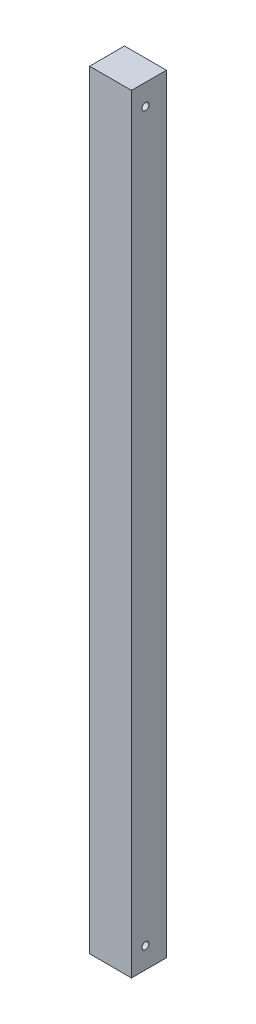
from build123d import *

# Parameters (mm, degrees)
SKETCH1_W           = 30
SKETCH1_H           = 25
BOSS_EXTRUDE1_DEPTH = 550
SKETCH2_R           = 2.5
CUT_EXTRUDE1_DEPTH  = 31


with BuildPart() as part:
    # Sketch1 → Boss-Extrude1 (new body)
    with BuildSketch(Plane(origin=(0, 0, 0), x_dir=(1, 0, 0), z_dir=(0, 1, 0))):
        with Locations((15, 17.5)):
            Rectangle(SKETCH1_W, SKETCH1_H)
    extrude(amount=BOSS_EXTRUDE1_DEPTH)

    # Sketch2 → Cut-Extrude1 (cut, through all)
    with BuildSketch(Plane(origin=(30, 0, 0), x_dir=(0, 0, -1), z_dir=(1, 0, 0))):
        with Locations((15, 15)):
            Circle(SKETCH2_R)
        with Locations((15, 535)):
            Circle(SKETCH2_R)
    extrude(amount=-CUT_EXTRUDE1_DEPTH, mode=Mode.SUBTRACT)


solid = part.part
